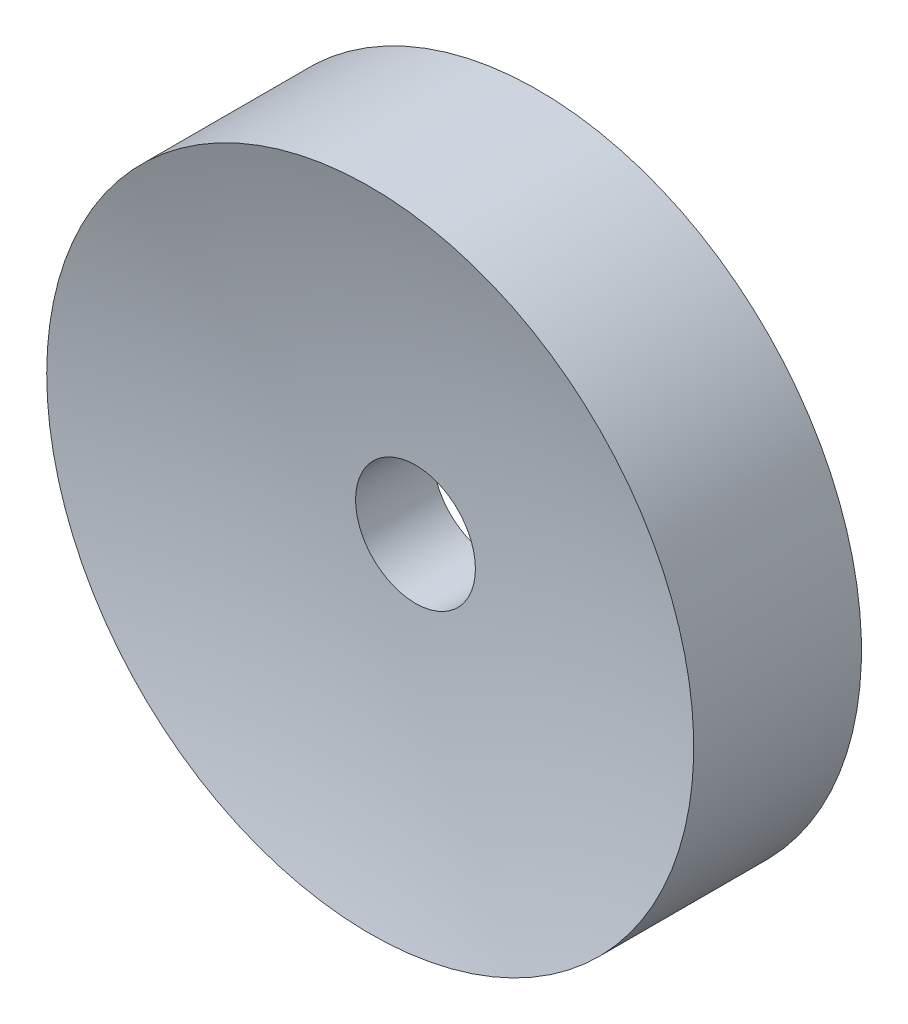
from build123d import *

# Parameters (mm, degrees)
SKETCH1_R           = 6.75
SKETCH1_R_2         = 1.25
BOSS_EXTRUDE1_DEPTH = 1.75


with BuildPart() as part:
    # Sketch1 → Boss-Extrude1 (new, symmetric)
    with BuildSketch(Plane.XY):
        Circle(SKETCH1_R)
        Circle(SKETCH1_R_2, mode=Mode.SUBTRACT)
    extrude(amount=BOSS_EXTRUDE1_DEPTH, both=True)

    # Sketch2 → Cut-Revolve1 (revolve, cut)
    with BuildSketch(Plane(origin=(0, 0, 0), x_dir=(1, 0, 0), z_dir=(0, 1, 0))):
        with BuildLine():
            Line((0, 1.75), (-6.75, 1.75))
            ThreePointArc((-6.75, 1.75), (-3.410178727, 1.018421792), (0, 0.772873706))
            Line((0, 0.772873706), (0, 1.75))
        make_face()
    cut_revolve1 = revolve(axis=Axis((0, 0, -3.982137232), (0, 0, 1)), mode=Mode.SUBTRACT)

    # Mirror1: Cut-Revolve1 across plane
    add(cut_revolve1.mirror(Plane.XY), mode=Mode.SUBTRACT)


solid = part.part
